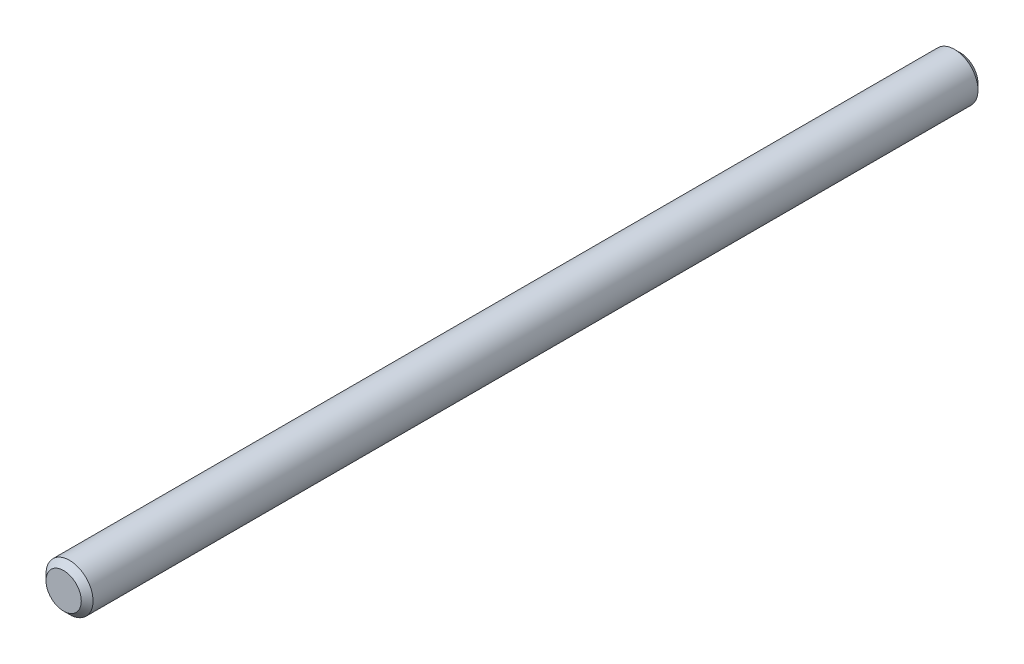
from build123d import *


with BuildPart() as part:
    # Sketch1 → Revolve1 (revolve)
    with BuildSketch(Plane(origin=(0, 0, 0), x_dir=(1, 0, 0), z_dir=(0, 1, 0))):
        Polygon((1.18618, 0), (0, 0), (0, -60.325), (1.18618, -60.325), (1.58242, -59.92876), (1.58242, -0.39624), align=None)
    revolve(axis=Axis((0, 0, 0), (0, 0, 1)))


solid = part.part
